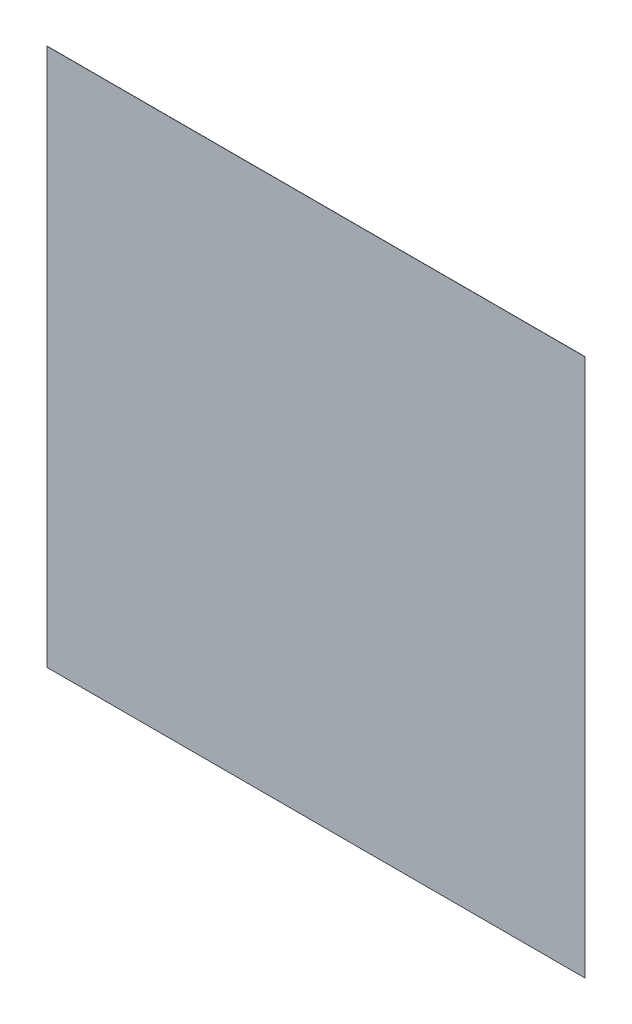
from build123d import *

# Parameters (mm, degrees)
SKETCH1_W           = 304.8
SKETCH1_H           = 304.8
BOSS_EXTRUDE1_DEPTH = 0.1


with BuildPart() as part:
    # Sketch1 → Boss-Extrude1 (new body)
    with BuildSketch(Plane.XY):
        Rectangle(SKETCH1_W, SKETCH1_H)
    extrude(amount=-BOSS_EXTRUDE1_DEPTH)


solid = part.part
